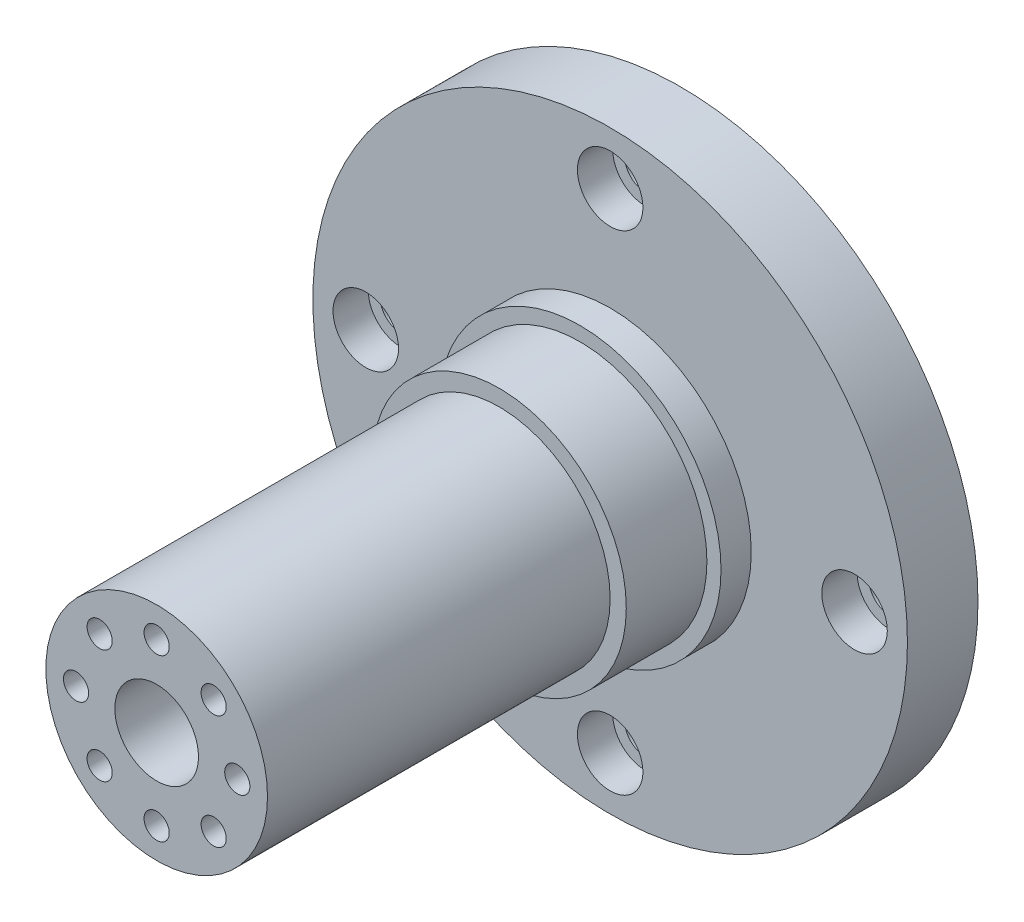
from build123d import *

# Parameters (mm, degrees)
SKETCH2_R           = 29.5
BOSS_EXTRUDE1_DEPTH = 7
SKETCH3_R           = 14
BOSS_EXTRUDE2_DEPTH = 3
SKETCH5_R           = 12.6
BOSS_EXTRUDE3_DEPTH = 8
SKETCH6_R           = 11
BOSS_EXTRUDE4_DEPTH = 34
SKETCH7_R           = 2.1
CUT_EXTRUDE1_DEPTH  = 33.8
SKETCH8_R           = 1.25
CUT_EXTRUDE2_DEPTH  = 19.2
SKETCH9_R           = 4.15
CUT_EXTRUDE3_DEPTH  = 9
SKETCH10_R          = 3.25
CUT_EXTRUDE4_DEPTH  = 3.5
SKETCH11_R          = 2.07
CUT_EXTRUDE5_DEPTH  = 4.5


with BuildPart() as part:
    # Sketch2 → Boss-Extrude1 (new body)
    with BuildSketch(Plane.XY):
        Circle(SKETCH2_R)
    extrude(amount=BOSS_EXTRUDE1_DEPTH)

    # Sketch3 → Boss-Extrude2 (add)
    with BuildSketch(Plane.XY.offset(7)):
        Circle(SKETCH3_R)
    extrude(amount=BOSS_EXTRUDE2_DEPTH)

    # Sketch5 → Boss-Extrude3 (add)
    with BuildSketch(Plane.XY.offset(10)):
        Circle(SKETCH5_R)
    extrude(amount=BOSS_EXTRUDE3_DEPTH)

    # Sketch6 → Boss-Extrude4 (add)
    with BuildSketch(Plane.XY.offset(18)):
        Circle(SKETCH6_R)
    extrude(amount=BOSS_EXTRUDE4_DEPTH)

    # Sketch7 → Cut-Extrude1 (cut)
    with BuildSketch(Plane(origin=(0, 0, 0), x_dir=(-1, 0, 0), z_dir=(0, 0, -1))):
        with Locations((8, 0)):
            Circle(SKETCH7_R)
        with Locations((5.656854249, -5.656854249)):
            Circle(SKETCH7_R)
        with Locations((0, -8)):
            Circle(SKETCH7_R)
        with Locations((-5.656854249, -5.656854249)):
            Circle(SKETCH7_R)
        with Locations((-8, 0)):
            Circle(SKETCH7_R)
        with Locations((-5.656854249, 5.656854249)):
            Circle(SKETCH7_R)
        with Locations((0, 8)):
            Circle(SKETCH7_R)
        with Locations((5.656854249, 5.656854249)):
            Circle(SKETCH7_R)
    extrude(amount=-CUT_EXTRUDE1_DEPTH, mode=Mode.SUBTRACT)

    # Sketch8 → Cut-Extrude2 (cut, through all)
    with BuildSketch(Plane(origin=(0, 0, 33.8), x_dir=(-1, 0, 0), z_dir=(0, 0, -1))):
        with Locations((-8, 0)):
            Circle(SKETCH8_R)
        with Locations((-5.656854249, 5.656854249)):
            Circle(SKETCH8_R)
        with Locations((0, 8)):
            Circle(SKETCH8_R)
        with Locations((5.656854249, 5.656854249)):
            Circle(SKETCH8_R)
        with Locations((8, 0)):
            Circle(SKETCH8_R)
        with Locations((5.656854249, -5.656854249)):
            Circle(SKETCH8_R)
        with Locations((0, -8)):
            Circle(SKETCH8_R)
        with Locations((-5.656854249, -5.656854249)):
            Circle(SKETCH8_R)
    extrude(amount=-CUT_EXTRUDE2_DEPTH, mode=Mode.SUBTRACT)

    # Sketch9 → Cut-Extrude3 (cut)
    with BuildSketch(Plane.XY.offset(52)):
        Circle(SKETCH9_R)
    extrude(amount=-CUT_EXTRUDE3_DEPTH, mode=Mode.SUBTRACT)

    # Sketch10 → Cut-Extrude4 (cut)
    with BuildSketch(Plane.XY.offset(7)):
        with Locations((-24.25, 0)):
            Circle(SKETCH10_R)
        with Locations((0, 24.25)):
            Circle(SKETCH10_R)
        with Locations((24.25, 0)):
            Circle(SKETCH10_R)
        with Locations((0, -24.25)):
            Circle(SKETCH10_R)
    extrude(amount=-CUT_EXTRUDE4_DEPTH, mode=Mode.SUBTRACT)

    # Sketch11 → Cut-Extrude5 (cut, through all)
    with BuildSketch(Plane.XY.offset(3.5)):
        with Locations((0, 24.25)):
            Circle(SKETCH11_R)
        with Locations((24.25, 0)):
            Circle(SKETCH11_R)
        with Locations((0, -24.25)):
            Circle(SKETCH11_R)
        with Locations((-24.25, 0)):
            Circle(SKETCH11_R)
    extrude(amount=-CUT_EXTRUDE5_DEPTH, mode=Mode.SUBTRACT)


solid = part.part
